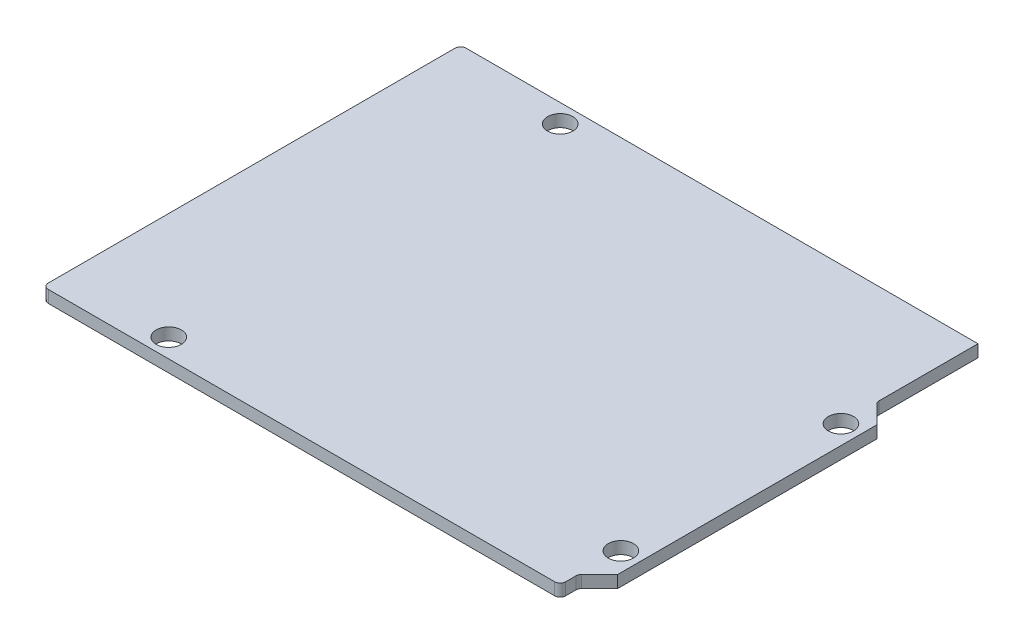
from build123d import *

# Parameters (mm, degrees)
ESQUISSE1_R        = 1.6
BOSS_EXTRU_1_DEPTH = 1.55
CONG_1_R           = 0.7


with BuildPart() as part:
    # Esquisse1 → Boss.-Extru.1 (new body)
    with BuildSketch(Plane(origin=(0, 0, 0), x_dir=(1, 0, 0), z_dir=(0, 1, 0))):
        Polygon((65.7, 53.05), (65.7, 40.2), (68.2, 37.7), (68.2, 4.8), (65.7, 2.3), (65.7, 0), (0, 0), (0, 53.05), align=None)
        with Locations((15, 50.7)):
            Circle(ESQUISSE1_R, mode=Mode.SUBTRACT)
        with Locations((13.6, 2.4)):
            Circle(ESQUISSE1_R, mode=Mode.SUBTRACT)
        with Locations((65.8, 7.6)):
            Circle(ESQUISSE1_R, mode=Mode.SUBTRACT)
        with Locations((65.8, 35.55)):
            Circle(ESQUISSE1_R, mode=Mode.SUBTRACT)
    extrude(amount=BOSS_EXTRU_1_DEPTH)

    # Congé1
    cong_1_edges = [part.edges().sort_by_distance(p)[0] for p in [
        (0, 0.775, -53.05),
        (65.7, 0.775, -40.2),
        (65.7, 0.775, -2.3),
        (65.7, 0.775, 0),
        (0, 0.775, 0),
    ]]
    fillet(cong_1_edges, radius=CONG_1_R)


solid = part.part
